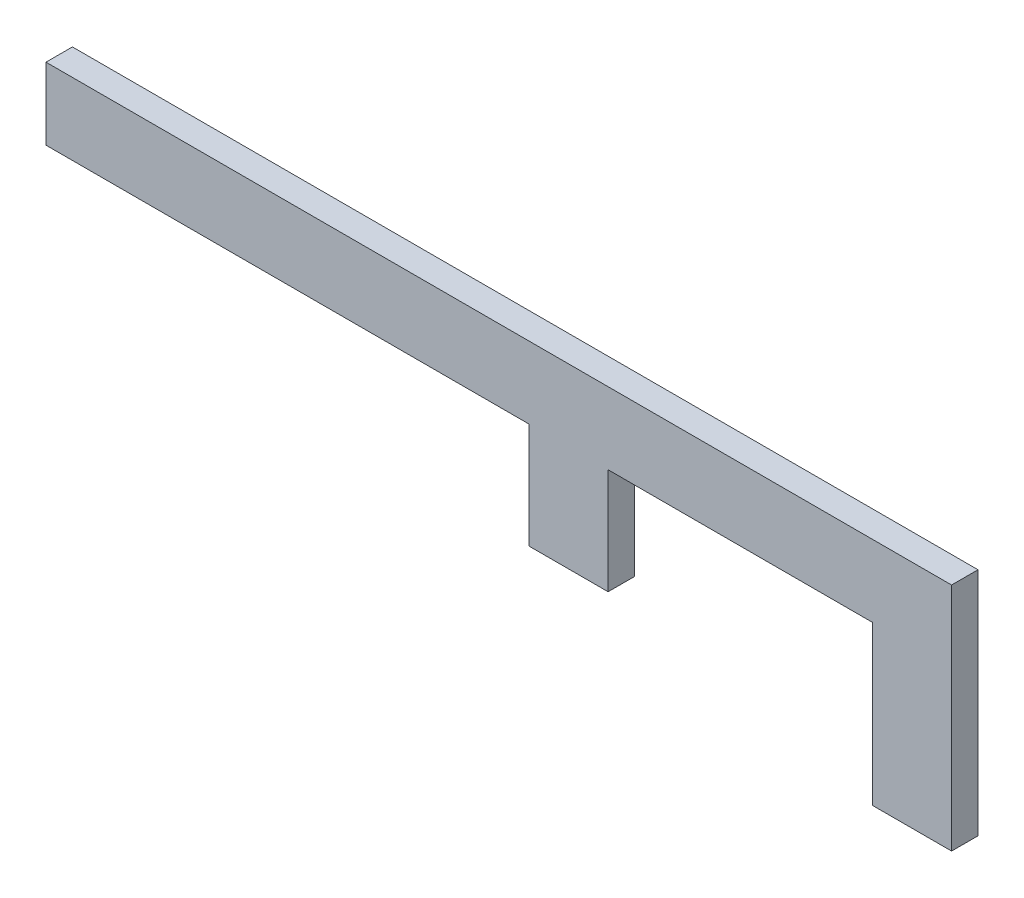
from build123d import *

# Parameters (mm, degrees)
BOSS_EXTRUDE1_DEPTH = 10
SKETCH2_W           = 30
SKETCH2_H           = 10
BOSS_EXTRUDE2_DEPTH = 60
SKETCH3_W           = 30
SKETCH3_H           = 10
BOSS_EXTRUDE3_DEPTH = 40


with BuildPart() as part:
    # Sketch1 → Boss-Extrude1 (new body)
    with BuildSketch(Plane.XY):
        Polygon((0, 0), (257.754406597, 0), (257.754406597, -27.219263415), (18.493720775, -27.219263415), (-56.767393161, -27.219263415), (-80, -27.219263415), (-85, -27.219263415), (-85, 0), (-80, 0), (-70, 0), align=None)
    extrude(amount=BOSS_EXTRUDE1_DEPTH)

    # Sketch2 → Boss-Extrude2 (add)
    with BuildSketch(Plane(origin=(0, -27.219263415, 0), x_dir=(-1, 0, 0), z_dir=(0, -1, 0))):
        with Locations((-242.754406597, -5)):
            Rectangle(SKETCH2_W, SKETCH2_H)
    extrude(amount=BOSS_EXTRUDE2_DEPTH)

    # Sketch3 → Boss-Extrude3 (add)
    with BuildSketch(Plane(origin=(0, -27.219263415, 0), x_dir=(-1, 0, 0), z_dir=(0, -1, 0))):
        with Locations((-112.754406597, -5)):
            Rectangle(SKETCH3_W, SKETCH3_H)
    extrude(amount=BOSS_EXTRUDE3_DEPTH)


solid = part.part
